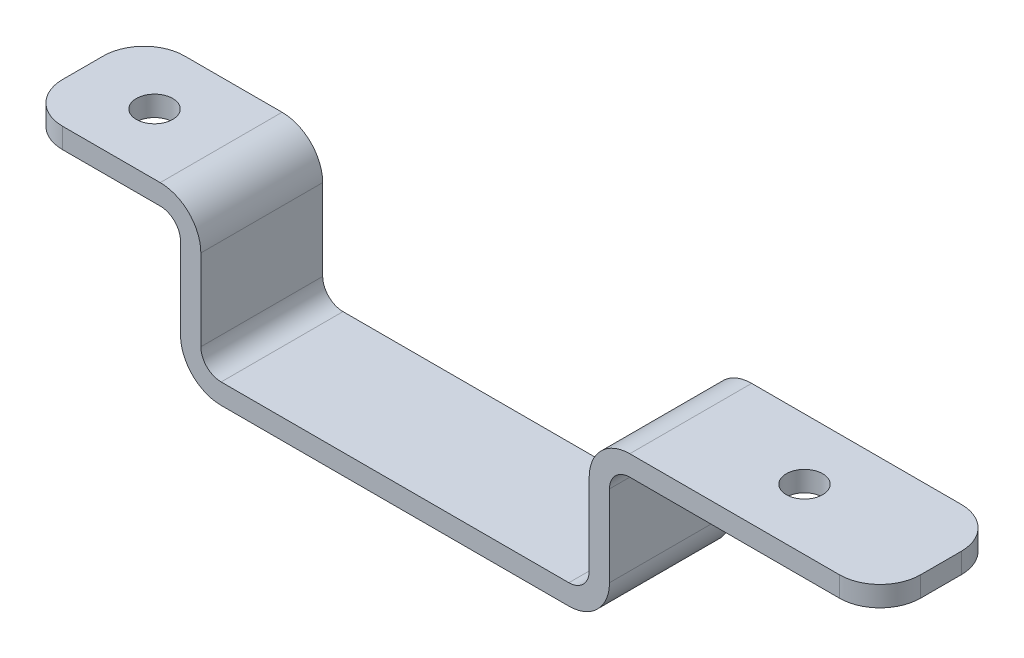
from build123d import *

# Parameters (mm, degrees)
BOSS_EXTRUDE1_DEPTH = 4.7625
FILLET1_R           = 1.5875
FILLET2_R           = 3.175
FILLET3_R           = 3.175
HOLE1_D             = 2.8448
HOLE2_D             = 2.8448


with BuildPart() as part:
    # Sketch1 → Boss-Extrude1 (new body, symmetric)
    with BuildSketch(Plane.XY):
        Polygon((-29.1465, 11.1125), (-16.764, 11.1125), (-16.764, 0), (16.764, 0), (16.764, 11.1125), (37.9095, 11.1125), (37.9095, 12.7), (15.1765, 12.7), (15.1765, 1.5875), (-15.1765, 1.5875), (-15.1765, 12.7), (-29.1465, 12.7), align=None)
    extrude(amount=BOSS_EXTRUDE1_DEPTH, both=True)

    # Fillet1
    fillet1_edges = [part.edges().sort_by_distance(p)[0] for p in [
        (-15.1765, 1.5875, 0),
        (15.1765, 1.5875, 0),
        (16.764, 11.1125, 0),
        (-16.764, 11.1125, 0),
    ]]
    fillet(fillet1_edges, radius=FILLET1_R)

    # Fillet2
    fillet2_edges = [part.edges().sort_by_distance(p)[0] for p in [
        (-15.1765, 12.7, 0),
        (15.1765, 12.7, 0),
        (16.764, 0, 0),
        (-16.764, 0, 0),
    ]]
    fillet(fillet2_edges, radius=FILLET2_R)

    # Fillet3
    fillet3_edges = [part.edges().sort_by_distance(p)[0] for p in [
        (37.9095, 11.90625, -4.7625),
        (-29.1465, 11.90625, -4.7625),
        (37.9095, 11.90625, 4.7625),
        (-29.1465, 11.90625, 4.7625),
    ]]
    fillet(fillet3_edges, radius=FILLET3_R)

    # Hole1 (through all)
    with Locations(Plane.XZ.offset(-11.1125)):
        with Locations((27.2415, 0)):
            Hole(HOLE1_D / 2)

    # Hole2 (through all)
    with Locations(Plane.XZ.offset(-11.1125)):
        with Locations((-23.5585, 0)):
            Hole(HOLE2_D / 2)


solid = part.part
